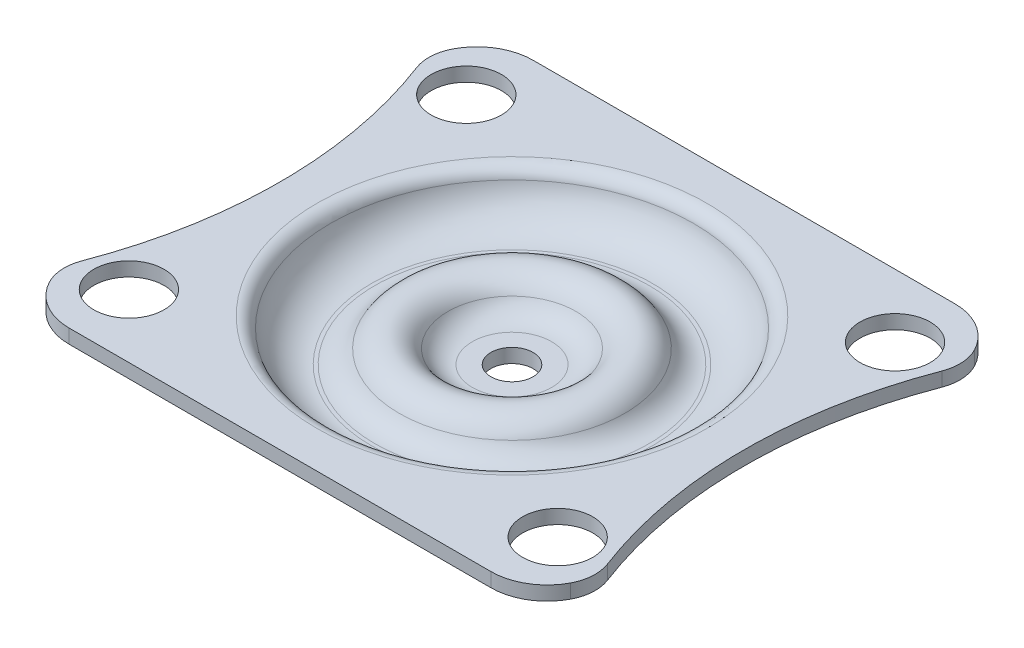
from build123d import *

# Parameters (mm, degrees)
ESQUISSE2_R        = 15
ESQUISSE2_R_2      = 2.5
BOSS_EXTRU_1_DEPTH = 1


with BuildPart() as part:
    # Esquisse1 → Révol.-Mince1 (revolve)
    with BuildSketch(Plane.XY):
        with BuildLine():
            Line((-15, 0), (-13.872983346, 0))
            ThreePointArc((-13.872983346, 0), (-13.260610911, -0.209430585), (-12.90473751, -0.75))
            ThreePointArc((-12.90473751, -0.75), (-11.837117307, -2.371708245), (-10, -3))
            Line((-10, -3), (-9.75, -3))
            ThreePointArc((-9.75, -3), (-8.75, -2.732050808), (-8.017949192, -2))
            ThreePointArc((-8.017949192, -2), (-6.285898385, -1), (-4.553847577, -2))
            ThreePointArc((-4.553847577, -2), (-3.82179677, -2.732050808), (-2.82179677, -3))
            Line((-2.82179677, -3), (-1.5, -3))
            Line((-1.5, -3), (-1.5, -4))
            Line((-1.5, -4), (-2.82179677, -4))
            ThreePointArc((-2.82179677, -4), (-4.32179677, -3.598076211), (-5.419872981, -2.5))
            ThreePointArc((-5.419872981, -2.5), (-6.285898385, -2), (-7.151923789, -2.5))
            ThreePointArc((-7.151923789, -2.5), (-8.25, -3.598076211), (-9.75, -4))
            Line((-9.75, -4), (-10, -4))
            ThreePointArc((-10, -4), (-12.449489743, -3.16227766), (-13.872983346, -1))
            Line((-13.872983346, -1), (-15, -1))
            Line((-15, -1), (-15, 0))
        make_face()
    revolve(axis=Axis((0, 5.373737374, 0), (0, -1, 0)))

    # Esquisse2 → Boss.-Extru.1 (add)
    with BuildSketch(Plane(origin=(0, 0, 0), x_dir=(1, 0, 0), z_dir=(0, 1, 0))):
        with BuildLine():
            Line((-15, 16.5), (15, 16.5))
            ThreePointArc((15, 16.5), (17.057983022, 15.929971703), (18.529411765, 14.382352941))
            ThreePointArc((18.529411765, 14.382352941), (18.87633895, 13.160450763), (18.68654311, 11.90451249))
            ThreePointArc((18.68654311, 11.90451249), (16.5, 0), (18.68654311, -11.90451249))
            ThreePointArc((18.68654311, -11.90451249), (18.87633895, -13.160450763), (18.529411765, -14.382352941))
            ThreePointArc((18.529411765, -14.382352941), (17.057983022, -15.929971703), (15, -16.5))
            Line((15, -16.5), (-15, -16.5))
            ThreePointArc((-15, -16.5), (-17.057983022, -15.929971703), (-18.529411765, -14.382352941))
            ThreePointArc((-18.529411765, -14.382352941), (-18.87633895, -13.160450763), (-18.68654311, -11.90451249))
            ThreePointArc((-18.68654311, -11.90451249), (-16.5, 0), (-18.68654311, 11.90451249))
            ThreePointArc((-18.68654311, 11.90451249), (-18.87633895, 13.160450763), (-18.529411765, 14.382352941))
            ThreePointArc((-18.529411765, 14.382352941), (-17.057983022, 15.929971703), (-15, 16.5))
        make_face()
        Circle(ESQUISSE2_R, mode=Mode.SUBTRACT)
        with Locations((-15.25, 12)):
            Circle(ESQUISSE2_R_2, mode=Mode.SUBTRACT)
        with Locations((-15.25, -12)):
            Circle(ESQUISSE2_R_2, mode=Mode.SUBTRACT)
        with Locations((15.25, 12)):
            Circle(ESQUISSE2_R_2, mode=Mode.SUBTRACT)
        with Locations((15.25, -12)):
            Circle(ESQUISSE2_R_2, mode=Mode.SUBTRACT)
    extrude(amount=-BOSS_EXTRU_1_DEPTH)


solid = part.part
